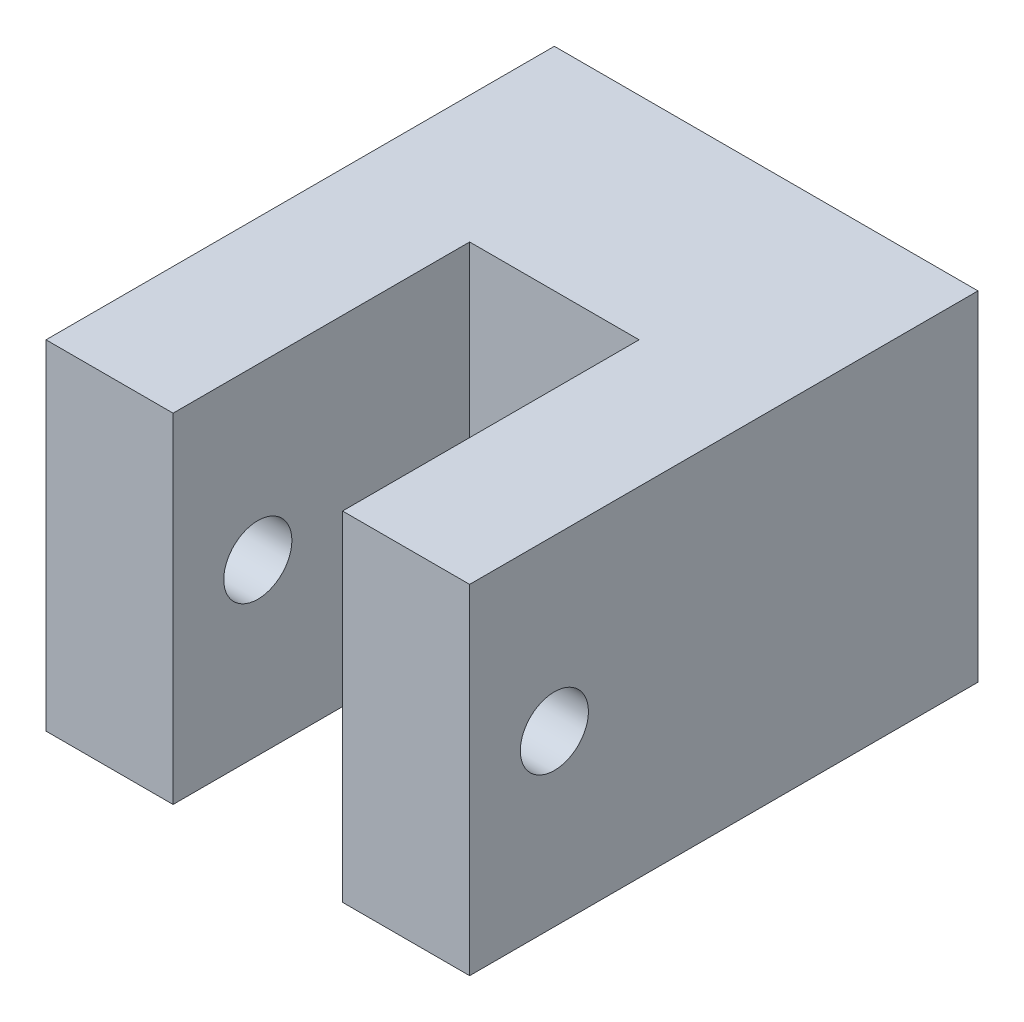
from build123d import *

# Parameters (mm, degrees)
SKETCH1_W                       = 31.75
SKETCH1_H                       = 25.4
BOSS_EXTRUDE1_DEPTH             = 38.1
F_1_4_0_25_DIAMETER_HOLE1_D     = 6.35
F_1_4_0_25_DIAMETER_HOLE1_DEPTH = 12.7
F_1_4_0_25_DIAMETER_HOLE1_TIP   = 1.907732465
SKETCH5_W                       = 12.7
SKETCH5_H                       = 22.225
CUT_EXTRUDE2_DEPTH              = 26.4
F_10_CLEARANCE_HOLE1_D          = 5.1054


with BuildPart() as part:
    # Sketch1 → Boss-Extrude1 (new body)
    with BuildSketch(Plane.XY):
        with Locations((15.875, 12.7)):
            Rectangle(SKETCH1_W, SKETCH1_H)
    extrude(amount=BOSS_EXTRUDE1_DEPTH)

    # 1/4 (0.25) Diameter Hole1
    with Locations(Plane(origin=(0, 0, 0), x_dir=(-1, 0, 0), z_dir=(0, 0, -1))):
        with Locations((-25.4, 12.7), (-6.35, 12.7)):
            Hole(F_1_4_0_25_DIAMETER_HOLE1_D / 2, depth=F_1_4_0_25_DIAMETER_HOLE1_DEPTH)
            with Locations((0, 0, -(F_1_4_0_25_DIAMETER_HOLE1_DEPTH + F_1_4_0_25_DIAMETER_HOLE1_TIP / 2))):  # 118° drill point
                Cone(0, F_1_4_0_25_DIAMETER_HOLE1_D / 2, F_1_4_0_25_DIAMETER_HOLE1_TIP, mode=Mode.SUBTRACT)

    # Sketch5 → Cut-Extrude2 (cut, through all)
    with BuildSketch(Plane(origin=(0, 25.4, 0), x_dir=(1, 0, 0), z_dir=(0, 1, 0))):
        with Locations((15.875, -26.9875)):
            Rectangle(SKETCH5_W, SKETCH5_H)
    extrude(amount=-CUT_EXTRUDE2_DEPTH, mode=Mode.SUBTRACT)

    # #10 Clearance Hole1 (through all)
    with Locations(Plane(origin=(31.75, 0, 0), x_dir=(0, 0, -1), z_dir=(1, 0, 0))):
        with Locations((-31.75, 12.7)):
            Hole(F_10_CLEARANCE_HOLE1_D / 2)


solid = part.part
